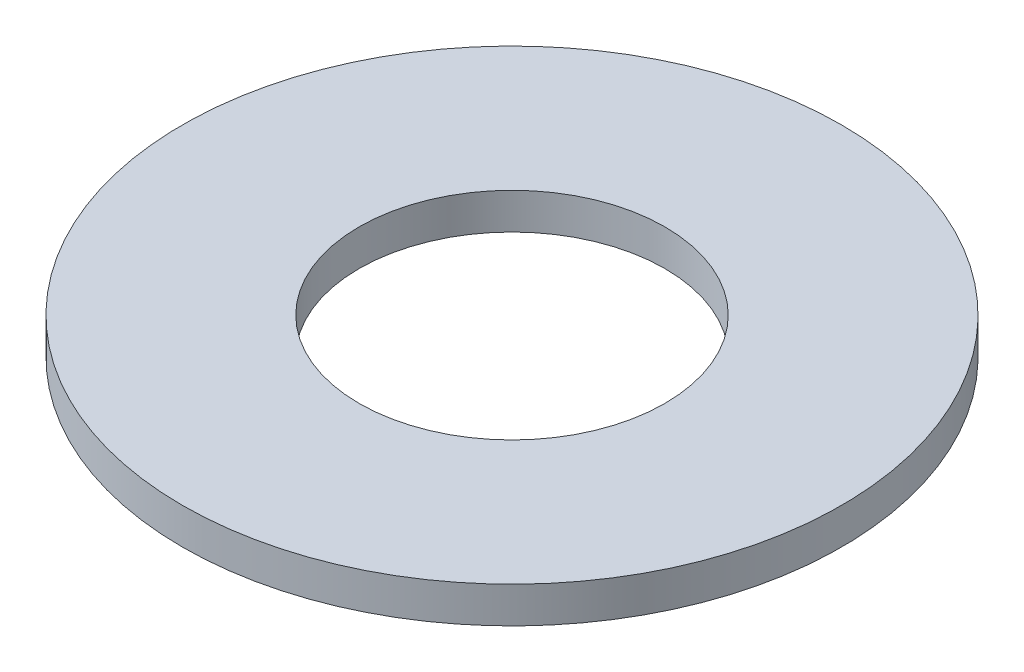
from build123d import *

# Parameters (mm, degrees)
SKETCH1_R           = 5.55625
BOSS_EXTRUDE1_DEPTH = 0.6096
SKETCH5_R           = 2.5781
CUT_EXTRUDE1_DEPTH  = 1.6096


with BuildPart() as part:
    # Sketch1 → Boss-Extrude1 (new body)
    with BuildSketch(Plane(origin=(0, 0, 0), x_dir=(1, 0, 0), z_dir=(0, 1, 0))):
        Circle(SKETCH1_R)
    extrude(amount=BOSS_EXTRUDE1_DEPTH)

    # Sketch5 → Cut-Extrude1 (cut, through all)
    with BuildSketch(Plane(origin=(0, 0.6096, 0), x_dir=(-1, 0, 0), z_dir=(0, 1, 0))):
        Circle(SKETCH5_R)
    extrude(amount=-CUT_EXTRUDE1_DEPTH, mode=Mode.SUBTRACT)


solid = part.part
